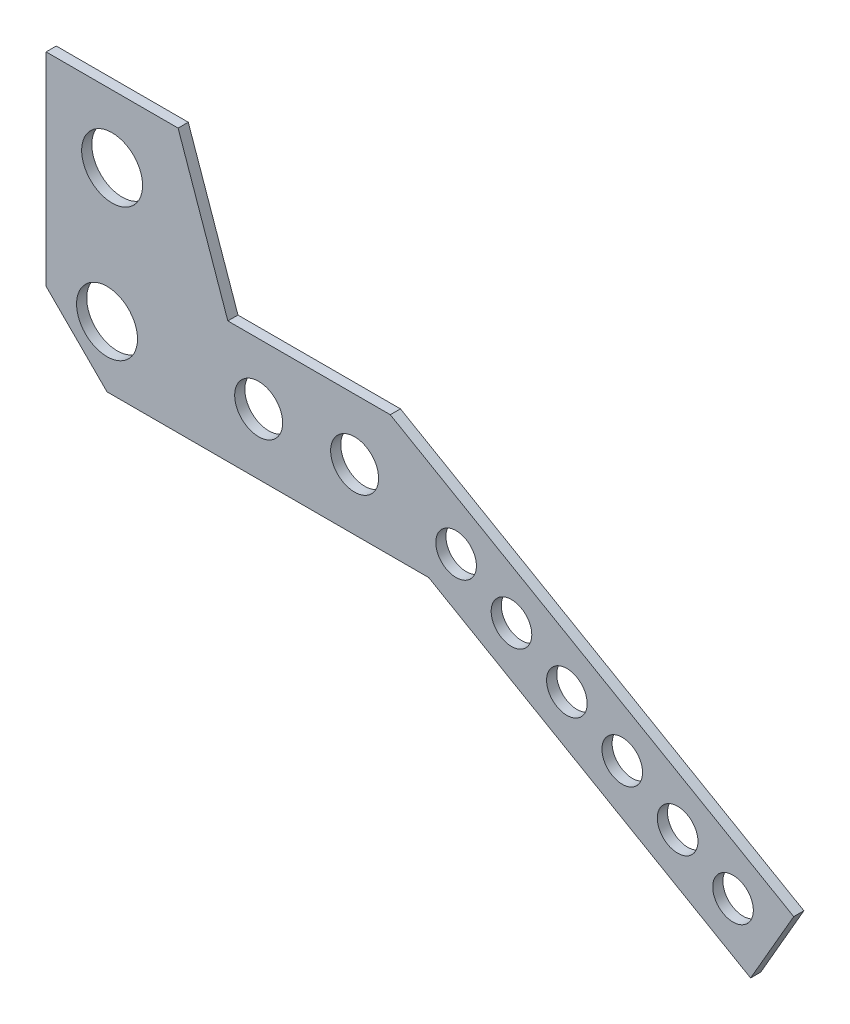
from build123d import *

# Parameters (mm, degrees)
SKETCH2_R           = 6.35
SKETCH2_R_2         = 7.5
SKETCH2_R_3         = 9.525
BOSS_EXTRUDE1_DEPTH = 3.175


with BuildPart() as part:
    # Sketch2 → Boss-Extrude1 (new body)
    with BuildSketch(Plane.XY):
        Polygon((-19.05, 82.55), (22.225, 82.55), (37.775682613, 38.1), (88.575682613, 38.1), (214.73506591, -34.738153907), (201.24131591, -58.110014492), (100.591818382, 0), (0, 0), (-19.05, 19.05), align=None)
        with Locations((109.151133068, 10.639517751)):
            Circle(SKETCH2_R, mode=Mode.SUBTRACT)
        with Locations((126.471641144, 0.639517751)):
            Circle(SKETCH2_R, mode=Mode.SUBTRACT)
        with Locations((143.79214922, -9.360482249)):
            Circle(SKETCH2_R, mode=Mode.SUBTRACT)
        with Locations((161.112657295, -19.360482249)):
            Circle(SKETCH2_R, mode=Mode.SUBTRACT)
        with Locations((178.433165371, -29.360482249)):
            Circle(SKETCH2_R, mode=Mode.SUBTRACT)
        with Locations((195.753673447, -39.360482249)):
            Circle(SKETCH2_R, mode=Mode.SUBTRACT)
        with Locations((47.415438379, 19.05)):
            Circle(SKETCH2_R_2, mode=Mode.SUBTRACT)
        with Locations((77.415438379, 19.05)):
            Circle(SKETCH2_R_2, mode=Mode.SUBTRACT)
        with Locations((0, 19.05)):
            Circle(SKETCH2_R_3, mode=Mode.SUBTRACT)
        with Locations((1.5875, 61.446195183)):
            Circle(SKETCH2_R_3, mode=Mode.SUBTRACT)
    extrude(amount=BOSS_EXTRUDE1_DEPTH)


solid = part.part
